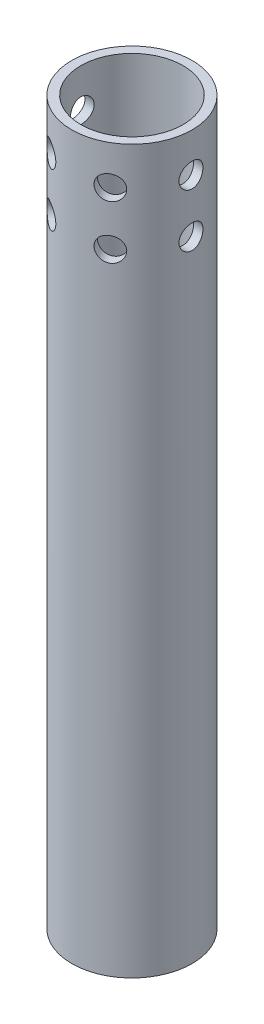
from build123d import *

# Parameters (mm, degrees)
SKETCH1_R                 = 9.525
BOSS_EXTRUDE1_DEPTH       = 114.3
SKETCH2_R                 = 8.095601674
CUT_EXTRUDE1_DEPTH        = 1
CUT_EXTRUDE1_DEPTH_BACK   = 107.95
SKETCH4_R                 = 1.89865
CUT_EXTRUDE2_DEPTH        = 114.3
CIRPATTERN1_COUNT         = 4
CIRPATTERN1_ANGLE         = 180
LPATTERN1_COUNT           = 2
LPATTERN1_PITCH           = 8.4582
LPATTERN1_COPY_1_SKETCH_R = 1.89865
LPATTERN1_COPY_1_DEPTH    = 114.3
LPATTERN1_COPY_2_SKETCH_R = 1.89865
LPATTERN1_COPY_2_DEPTH    = 114.3
LPATTERN1_COPY_3_SKETCH_R = 1.89865
LPATTERN1_COPY_3_DEPTH    = 114.3
SKETCH5_R                 = 2.921
CUT_EXTRUDE3_DEPTH        = 114.3


with BuildPart() as part:
    # Sketch1 → Boss-Extrude1 (new body)
    with BuildSketch(Plane(origin=(0, 0, 0), x_dir=(1, 0, 0), z_dir=(0, 1, 0))):
        Circle(SKETCH1_R)
    extrude(amount=BOSS_EXTRUDE1_DEPTH)

    # Sketch2 → Cut-Extrude1 (cut, two sides)
    with BuildSketch(Plane(origin=(0, 114.3, 0), x_dir=(1, 0, 0), z_dir=(0, 1, 0))) as cut_extrude1_sk:
        Circle(SKETCH2_R)
    extrude(amount=CUT_EXTRUDE1_DEPTH, mode=Mode.SUBTRACT)
    extrude(cut_extrude1_sk.sketch, amount=-CUT_EXTRUDE1_DEPTH_BACK, mode=Mode.SUBTRACT)

    # Sketch4 → Cut-Extrude2 (cut)
    with BuildSketch(Plane(origin=(0, 0, 0), x_dir=(0, 0, -1), z_dir=(1, 0, 0))):
        with Locations((0, 108.119085448)):
            Circle(SKETCH4_R)
    cut_extrude2 = extrude(amount=CUT_EXTRUDE2_DEPTH, mode=Mode.SUBTRACT)

    # CirPattern1: Cut-Extrude2 ×4 about axis
    cirpattern1_axis = Axis((0, 114.3, 0), (0, -1, 0))
    for i in range(1, CIRPATTERN1_COUNT):
        add(cut_extrude2.rotate(cirpattern1_axis, i * CIRPATTERN1_ANGLE / (CIRPATTERN1_COUNT - 1)), mode=Mode.SUBTRACT)

    # LPattern1: Cut-Extrude2 ×2
    with Locations(*[(0, -i * LPATTERN1_PITCH, 0) for i in range(1, LPATTERN1_COUNT)]):
        add(cut_extrude2, mode=Mode.SUBTRACT)

    # LPattern1 copy 1 sketch → LPattern1 copy 1 (cut)
    with BuildSketch(Plane(origin=(0, -8.4582, 0), x_dir=(0.866025404, 0, -0.5), z_dir=(0.5, 0, 0.866025404))):
        with Locations((0, 108.119085448)):
            Circle(LPATTERN1_COPY_1_SKETCH_R)
    extrude(amount=LPATTERN1_COPY_1_DEPTH, mode=Mode.SUBTRACT)

    # LPattern1 copy 2 sketch → LPattern1 copy 2 (cut)
    with BuildSketch(Plane(origin=(0, -8.4582, 0), x_dir=(0.866025404, 0, 0.5), z_dir=(-0.5, 0, 0.866025404))):
        with Locations((0, 108.119085448)):
            Circle(LPATTERN1_COPY_2_SKETCH_R)
    extrude(amount=LPATTERN1_COPY_2_DEPTH, mode=Mode.SUBTRACT)

    # LPattern1 copy 3 sketch → LPattern1 copy 3 (cut)
    with BuildSketch(Plane(origin=(0, -8.4582, 0), x_dir=(0, 0, 1), z_dir=(-1, 0, 0))):
        with Locations((0, 108.119085448)):
            Circle(LPATTERN1_COPY_3_SKETCH_R)
    extrude(amount=LPATTERN1_COPY_3_DEPTH, mode=Mode.SUBTRACT)

    # Sketch5 → Cut-Extrude3 (cut)
    with BuildSketch(Plane.XZ):
        Circle(SKETCH5_R)
    extrude(amount=-CUT_EXTRUDE3_DEPTH, mode=Mode.SUBTRACT)


solid = part.part
